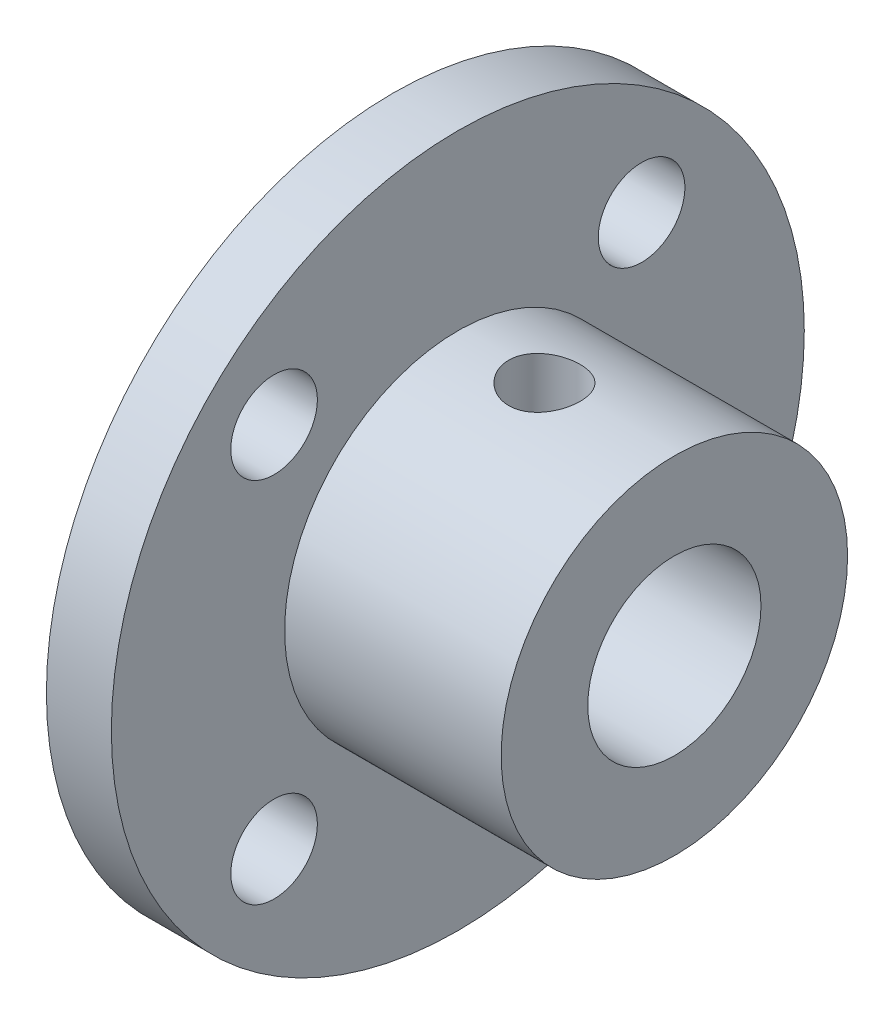
from build123d import *

# Parameters (mm, degrees)
SKETCH_1_R          = 8
SKETCH_1_R_2        = 4
EXTRUDE_1_DEPTH     = 10
SKETCH_2_R          = 16
SKETCH_2_R_2        = 4
EXTRUDE_2_DEPTH     = 3
CUT_EXTRUDE_1_REACH = 5
SKETCH_3_R          = 2


with BuildPart() as part:
    # 草图1 → 凸台-拉伸1 (new body)
    with BuildSketch(Plane(origin=(0, 0, 0), x_dir=(0, 0, -1), z_dir=(1, 0, 0))):
        Circle(SKETCH_1_R)
        Circle(SKETCH_1_R_2, mode=Mode.SUBTRACT)
    extrude(amount=EXTRUDE_1_DEPTH)

    # 草图2 → 凸台-拉伸2 (add)
    with BuildSketch(Plane.ZY):
        Circle(SKETCH_2_R)
        Circle(SKETCH_2_R_2, mode=Mode.SUBTRACT)
    extrude(amount=EXTRUDE_2_DEPTH)

    # 草图3 → 切除-拉伸1 (cut, up to next)
    with BuildSketch(Plane(origin=(0, 0, 0), x_dir=(0, 0, -1), z_dir=(1, 0, 0)), mode=Mode.PRIVATE) as cut_extrude_1_sk1:
        with Locations((-8.485281374, -8.485281374)):
            Circle(SKETCH_3_R)
    cut_extrude_1_tool1 = extrude(cut_extrude_1_sk1.sketch, amount=-CUT_EXTRUDE_1_REACH, mode=Mode.PRIVATE) & part.part
    add(cut_extrude_1_tool1.solids().sort_by_distance((0, -8.485281, 8.485281))[0], mode=Mode.SUBTRACT)
    # 草图3 → 切除-拉伸1 (cut, up to next)
    with BuildSketch(Plane(origin=(0, 0, 0), x_dir=(0, 0, -1), z_dir=(1, 0, 0)), mode=Mode.PRIVATE) as cut_extrude_1_sk2:
        with Locations((8.485281374, 8.485281374)):
            Circle(SKETCH_3_R)
    cut_extrude_1_tool2 = extrude(cut_extrude_1_sk2.sketch, amount=-CUT_EXTRUDE_1_REACH, mode=Mode.PRIVATE) & part.part
    add(cut_extrude_1_tool2.solids().sort_by_distance((0, 8.485281, -8.485281))[0], mode=Mode.SUBTRACT)
    # 草图3 → 切除-拉伸1 (cut, up to next)
    with BuildSketch(Plane(origin=(0, 0, 0), x_dir=(0, 0, -1), z_dir=(1, 0, 0)), mode=Mode.PRIVATE) as cut_extrude_1_sk3:
        with Locations((-8.485281374, 8.485281374)):
            Circle(SKETCH_3_R)
    cut_extrude_1_tool3 = extrude(cut_extrude_1_sk3.sketch, amount=-CUT_EXTRUDE_1_REACH, mode=Mode.PRIVATE) & part.part
    add(cut_extrude_1_tool3.solids().sort_by_distance((0, 8.485281, 8.485281))[0], mode=Mode.SUBTRACT)
    # 草图3 → 切除-拉伸1 (cut, up to next)
    with BuildSketch(Plane(origin=(0, 0, 0), x_dir=(0, 0, -1), z_dir=(1, 0, 0)), mode=Mode.PRIVATE) as cut_extrude_1_sk4:
        with Locations((8.485281374, -8.485281374)):
            Circle(SKETCH_3_R)
    cut_extrude_1_tool4 = extrude(cut_extrude_1_sk4.sketch, amount=-CUT_EXTRUDE_1_REACH, mode=Mode.PRIVATE) & part.part
    add(cut_extrude_1_tool4.solids().sort_by_distance((0, -8.485281, -8.485281))[0], mode=Mode.SUBTRACT)

    # 草图5 → M4 螺纹孔1 (revolve, cut)
    with BuildSketch(Plane(origin=(4.000350767, 0, 0), x_dir=(0, 0, -1), z_dir=(1, 0, 0))):
        Polygon((0, 0), (0, 12.491420021), (1.65, 11.5), (1.65, 0), align=None)
    revolve(axis=Axis((4.000350767, -6.35, 0), (0, 1, 0)), mode=Mode.SUBTRACT)


solid = part.part
